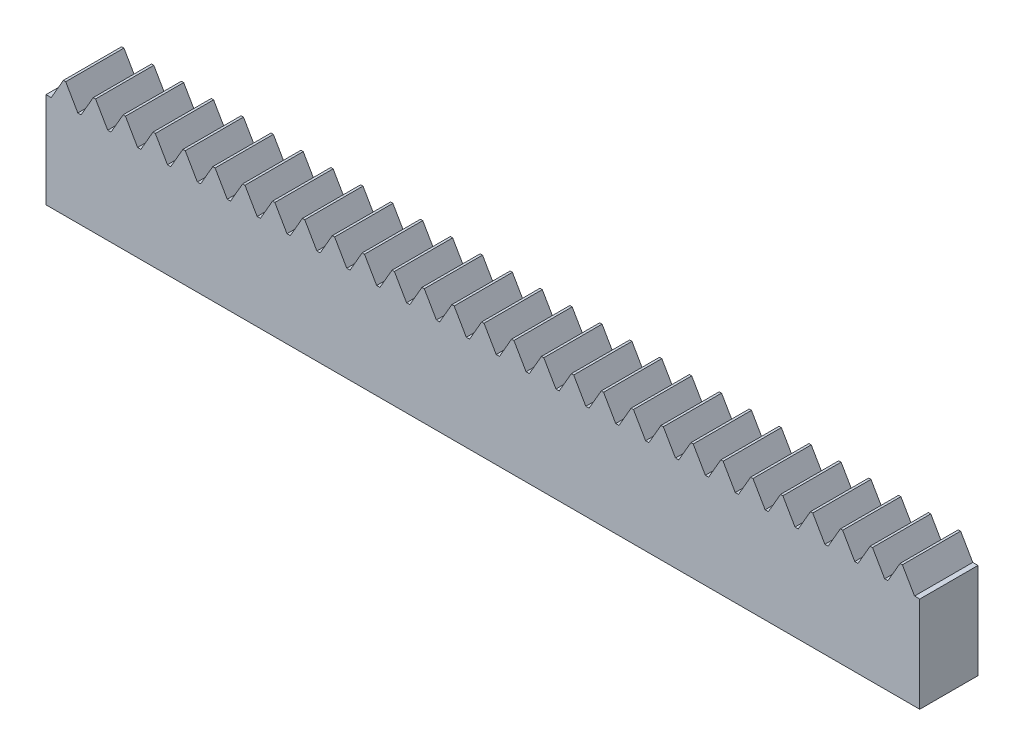
from build123d import *

# Parameters (mm, degrees)
BOSS_EXTRUDE1_DEPTH = 10


with BuildPart() as part:
    # Sketch1 → Boss-Extrude1 (new body)
    with BuildSketch(Plane.XY):
        Polygon((79.93, 0), (77.845765528, -3.61), (77.284234472, -3.61), (75.2, 0), (74.8, 0), (72.715765528, -3.61), (72.154234472, -3.61), (70.07, 0), (69.67, 0), (67.585765528, -3.61), (67.024234472, -3.61), (64.94, 0), (64.54, 0), (62.455765528, -3.61), (61.894234472, -3.61), (59.81, 0), (59.41, 0), (57.325765528, -3.61), (56.764234472, -3.61), (54.68, 0), (54.28, 0), (52.195765528, -3.61), (51.634234472, -3.61), (49.55, 0), (49.15, 0), (47.065765528, -3.61), (46.504234472, -3.61), (44.42, 0), (44.02, 0), (41.935765528, -3.61), (41.374234472, -3.61), (39.29, 0), (38.89, 0), (36.805765528, -3.61), (36.244234472, -3.61), (34.16, 0), (33.76, 0), (31.675765528, -3.61), (31.114234472, -3.61), (29.03, 0), (28.63, 0), (26.545765528, -3.61), (25.984234472, -3.61), (23.9, 0), (23.5, 0), (21.415765528, -3.61), (20.854234472, -3.61), (18.77, 0), (18.37, 0), (16.285765528, -3.61), (15.724234472, -3.61), (13.64, 0), (13.24, 0), (11.155765528, -3.61), (10.594234472, -3.61), (8.51, 0), (8.11, 0), (6.025765528, -3.61), (5.464234472, -3.61), (3.38, 0), (2.98, 0), (0.895765528, -3.61), (0, -3.61), (0, -20), (150, -20), (150, -3.61), (149.104234472, -3.61), (147.02, 0), (146.62, 0), (144.535765528, -3.61), (143.974234472, -3.61), (141.89, 0), (141.49, 0), (139.405765528, -3.61), (138.844234472, -3.61), (136.76, 0), (136.36, 0), (134.275765528, -3.61), (133.714234472, -3.61), (131.63, 0), (131.23, 0), (129.145765528, -3.61), (128.584234472, -3.61), (126.5, 0), (126.1, 0), (124.015765528, -3.61), (123.454234472, -3.61), (121.37, 0), (120.97, 0), (118.885765528, -3.61), (118.324234472, -3.61), (116.24, 0), (115.84, 0), (113.755765528, -3.61), (113.194234472, -3.61), (111.11, 0), (110.71, 0), (108.625765528, -3.61), (108.064234472, -3.61), (105.98, 0), (105.58, 0), (103.495765528, -3.61), (102.934234472, -3.61), (100.85, 0), (100.45, 0), (98.365765528, -3.61), (97.804234472, -3.61), (95.72, 0), (95.32, 0), (93.235765528, -3.61), (92.674234472, -3.61), (90.59, 0), (90.19, 0), (88.105765528, -3.61), (87.544234472, -3.61), (85.46, 0), (85.06, 0), (82.975765528, -3.61), (82.414234472, -3.61), (80.33, 0), align=None)
    extrude(amount=BOSS_EXTRUDE1_DEPTH)


solid = part.part
